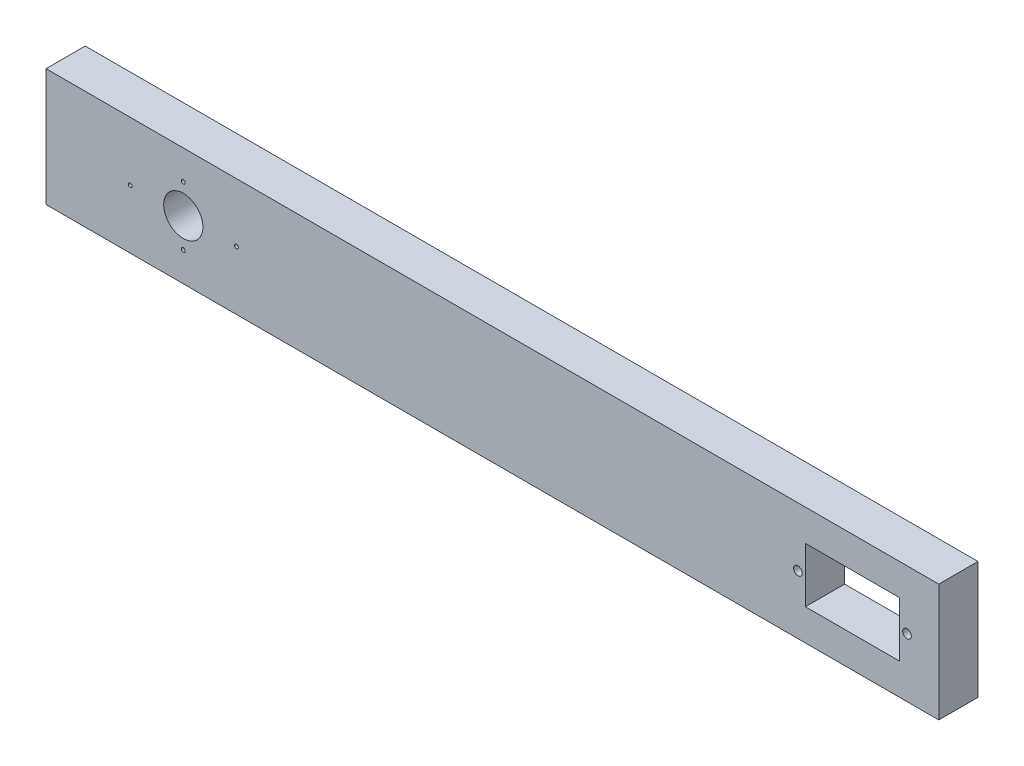
from build123d import *

# Parameters (mm, degrees)
SKETCH1_W           = 227.6
SKETCH1_H           = 30
SKETCH1_R           = 0.5
SKETCH1_R_2         = 5
SKETCH1_R_3         = 1.1
SKETCH1_W_2         = 24
SKETCH1_H_2         = 14
BOSS_EXTRUDE1_DEPTH = 10


with BuildPart() as part:
    # Sketch1 → Boss-Extrude1 (new body)
    with BuildSketch(Plane.XY):
        with Locations((113.8, 15)):
            Rectangle(SKETCH1_W, SKETCH1_H)
        with Locations((35, 7.47)):
            Circle(SKETCH1_R, mode=Mode.SUBTRACT)
        with Locations((21.47, 15)):
            Circle(SKETCH1_R, mode=Mode.SUBTRACT)
        with Locations((35, 15)):
            Circle(SKETCH1_R_2, mode=Mode.SUBTRACT)
        with Locations((48.53, 15)):
            Circle(SKETCH1_R, mode=Mode.SUBTRACT)
        with Locations((35, 22.53)):
            Circle(SKETCH1_R, mode=Mode.SUBTRACT)
        with Locations((219.5, 15)):
            Circle(SKETCH1_R_3, mode=Mode.SUBTRACT)
        with Locations((191.7, 15)):
            Circle(SKETCH1_R_3, mode=Mode.SUBTRACT)
        with Locations((205.6, 15)):
            Rectangle(SKETCH1_W_2, SKETCH1_H_2, mode=Mode.SUBTRACT)
    extrude(amount=BOSS_EXTRUDE1_DEPTH)


solid = part.part
